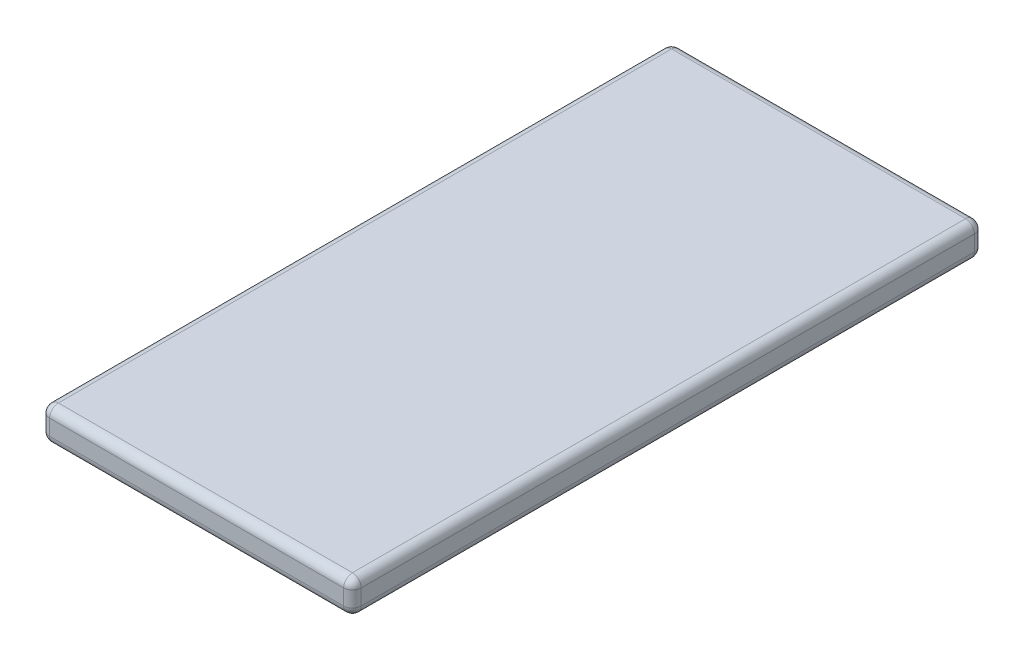
from build123d import *

# Parameters (mm, degrees)
SKETCH_1_W      = 70.94
SKETCH_1_H      = 143.59
EXTRUDE_1_DEPTH = 7.56
FILLET_1_R      = 2


with BuildPart() as part:
    # ｽｹｯﾁ1 → ﾎﾞｽ - 押し出し1 (new body)
    with BuildSketch(Plane(origin=(0, 0, 0), x_dir=(1, 0, 0), z_dir=(0, 1, 0))):
        Rectangle(SKETCH_1_W, SKETCH_1_H)
    extrude(amount=EXTRUDE_1_DEPTH)

    # ﾌｨﾚｯﾄ1
    fillet_1_edges = [part.edges().sort_by_distance(p)[0] for p in [
        (-35.47, 7.56, 0),
        (0, 7.56, 71.795),
        (35.47, 7.56, 0),
        (0, 0, 71.795),
        (-35.47, 0, 0),
        (0, 0, -71.795),
        (35.47, 0, 0),
        (0, 7.56, -71.795),
        (35.47, 3.78, 71.795),
        (-35.47, 3.78, 71.795),
        (-35.47, 3.78, -71.795),
        (35.47, 3.78, -71.795),
    ]]
    fillet(fillet_1_edges, radius=FILLET_1_R)


solid = part.part
